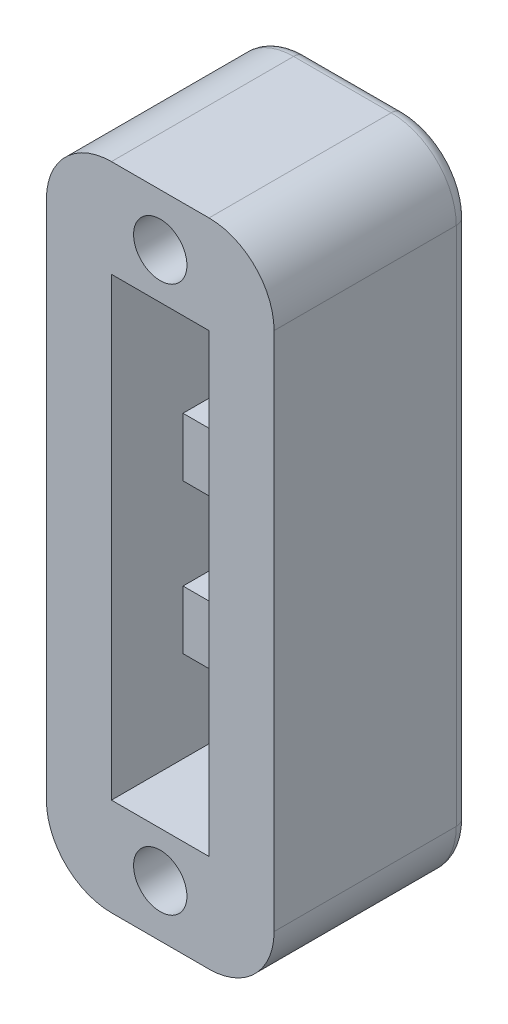
from build123d import *

# Parameters (mm, degrees)
SKETCH1_W           = 8.89
SKETCH1_H           = 7.62
BOSS_EXTRUDE1_DEPTH = 25.4
SKETCH2_W           = 3.81
SKETCH2_H           = 17.78
CUT_EXTRUDE1_DEPTH  = 5.334
SKETCH3_W           = 2.54
SKETCH3_H           = 2.286
SKETCH3_H_2         = 2.54
BOSS_EXTRUDE2_DEPTH = 3.81
SKETCH4_W           = 3.81
SKETCH4_H           = 3.556
CUT_EXTRUDE2_DEPTH  = 3.286
SKETCH5_R           = 1.0414
CUT_EXTRUDE4_DEPTH  = 8.62
FILLET3_R           = 2.54
FILLET2_R           = 0.508


with BuildPart() as part:
    # Sketch1 → Boss-Extrude1 (new body)
    with BuildSketch(Plane(origin=(0, 0, 0), x_dir=(1, 0, 0), z_dir=(0, 1, 0))):
        Rectangle(SKETCH1_W, SKETCH1_H)
    extrude(amount=BOSS_EXTRUDE1_DEPTH)

    # Sketch2 → Cut-Extrude1 (cut)
    with BuildSketch(Plane.XY.offset(3.81)):
        with Locations((0, 12.7)):
            Rectangle(SKETCH2_W, SKETCH2_H)
    extrude(amount=-CUT_EXTRUDE1_DEPTH, mode=Mode.SUBTRACT)

    # Sketch3 → Boss-Extrude2 (add)
    with BuildSketch(Plane.ZY.offset(-1.905)):
        with Locations((-0.254, 14.351)):
            Rectangle(SKETCH3_W, SKETCH3_H)
        with Locations((-0.254, 8.509)):
            Rectangle(SKETCH3_W, SKETCH3_H)
        with Locations((-0.254, 20.32)):
            Rectangle(SKETCH3_W, SKETCH3_H_2)
    extrude(amount=BOSS_EXTRUDE2_DEPTH)

    # Sketch4 → Cut-Extrude2 (cut, through all)
    with BuildSketch(Plane.XY.offset(-1.524)):
        with Locations((0, 5.588)):
            Rectangle(SKETCH4_W, SKETCH4_H)
    extrude(amount=-CUT_EXTRUDE2_DEPTH, mode=Mode.SUBTRACT)

    # Sketch5 → Cut-Extrude4 (cut, through all)
    with BuildSketch(Plane.XY.offset(3.81)):
        with Locations((0, 2.032)):
            Circle(SKETCH5_R)
        with Locations((0, 23.368)):
            Circle(SKETCH5_R)
    extrude(amount=-CUT_EXTRUDE4_DEPTH, mode=Mode.SUBTRACT)

    # Fillet3
    fillet3_edges = [part.edges().sort_by_distance(p)[0] for p in [
        (-4.445, 25.4, 0),
        (4.445, 25.4, 0),
        (-4.445, 0, 0),
        (4.445, 0, 0),
    ]]
    fillet(fillet3_edges, radius=FILLET3_R)

    # Fillet2
    fillet2_edges = [part.edges().sort_by_distance(p)[0] for p in [
        (0, 25.4, -3.81),
        (4.445, 12.7, -3.81),
        (-3.701051224, 24.656051224, -3.81),
        (3.701051224, 24.656051224, -3.81),
        (3.701051224, 0.743948776, -3.81),
        (-3.701051224, 0.743948776, -3.81),
        (-4.445, 12.7, -3.81),
        (0, 0, -3.81),
    ]]
    fillet(fillet2_edges, radius=FILLET2_R)


solid = part.part
